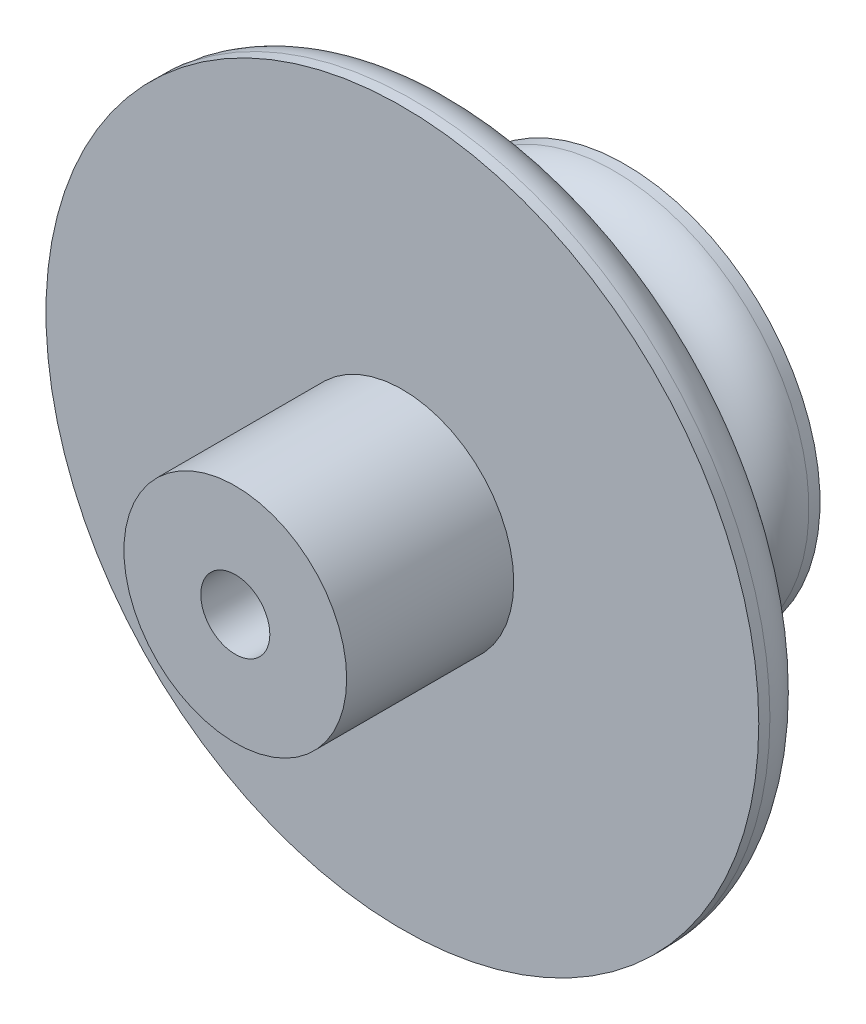
from build123d import *

# Parameters (mm, degrees)
SKETCH_1_R               = 10
SKETCH_1_R_2             = 3.1
EXTRUDE_1_DEPTH          = 15
SKETCH_2_R               = 32
EXTRUDE_2_DEPTH          = 5
SKETCH_3_R               = 7.5
EXTRUDE_3_DEPTH          = 10
SKETCH_4_R               = 17.5
EXTRUDE_4_DEPTH          = 5
SKETCH_5_R               = 1.85
CUT_EXTRUDE_1_DEPTH      = 33
SKETCH_5_3_R             = 1.25
CUT_EXTRUDE_2_DEPTH      = 33
CUT_EXTRUDE_2_DEPTH_BACK = 33
FILLET_1_R               = 4


with BuildPart() as part:
    # Sketch 1 → Extrude 1 (new body)
    with BuildSketch(Plane.XY):
        Circle(SKETCH_1_R)
        Circle(SKETCH_1_R_2, mode=Mode.SUBTRACT)
    extrude(amount=EXTRUDE_1_DEPTH)

    # Sketch 2 → Extrude 2 (add)
    with BuildSketch(Plane.XY):
        Circle(SKETCH_2_R)
    extrude(amount=-EXTRUDE_2_DEPTH)

    # Sketch 3 → Extrude 3 (add)
    with BuildSketch(Plane(origin=(0, 0, -5), x_dir=(-1, 0, 0), z_dir=(0, 0, -1))):
        Circle(SKETCH_3_R)
    extrude(amount=EXTRUDE_3_DEPTH)

    # Sketch 4 → Extrude 4 (add)
    with BuildSketch(Plane(origin=(0, 0, -15), x_dir=(-1, 0, 0), z_dir=(0, 0, -1))):
        Circle(SKETCH_4_R)
    extrude(amount=EXTRUDE_4_DEPTH)

    # Sketch 5 → Cut-Extrude 1 (cut, through all)
    with BuildSketch(Plane(origin=(0, 0, 0), x_dir=(1, 0, 0), z_dir=(0, 1, 0))):
        with Locations((0, -8.5)):
            Circle(SKETCH_5_R)
    extrude(amount=-CUT_EXTRUDE_1_DEPTH, mode=Mode.SUBTRACT)

    # Sketch 5_3 → Cut-Extrude 2 (cut, two sides)
    with BuildSketch(Plane(origin=(0, 0, 0), x_dir=(1, 0, 0), z_dir=(0, 1, 0))) as cut_extrude_2_sk:
        with Locations((0, 10)):
            Circle(SKETCH_5_3_R)
    extrude(amount=CUT_EXTRUDE_2_DEPTH, mode=Mode.SUBTRACT)
    extrude(cut_extrude_2_sk.sketch, amount=-CUT_EXTRUDE_2_DEPTH_BACK, mode=Mode.SUBTRACT)

    # Fillet 1
    fillet_1_edges = [part.edges().sort_by_distance(p)[0] for p in [
        (-32, 0, -5),
        (7.5, 0, -5),
        (7.5, 0, -15),
        (17.5, 0, -15),
    ]]
    fillet(fillet_1_edges, radius=FILLET_1_R)


solid = part.part
